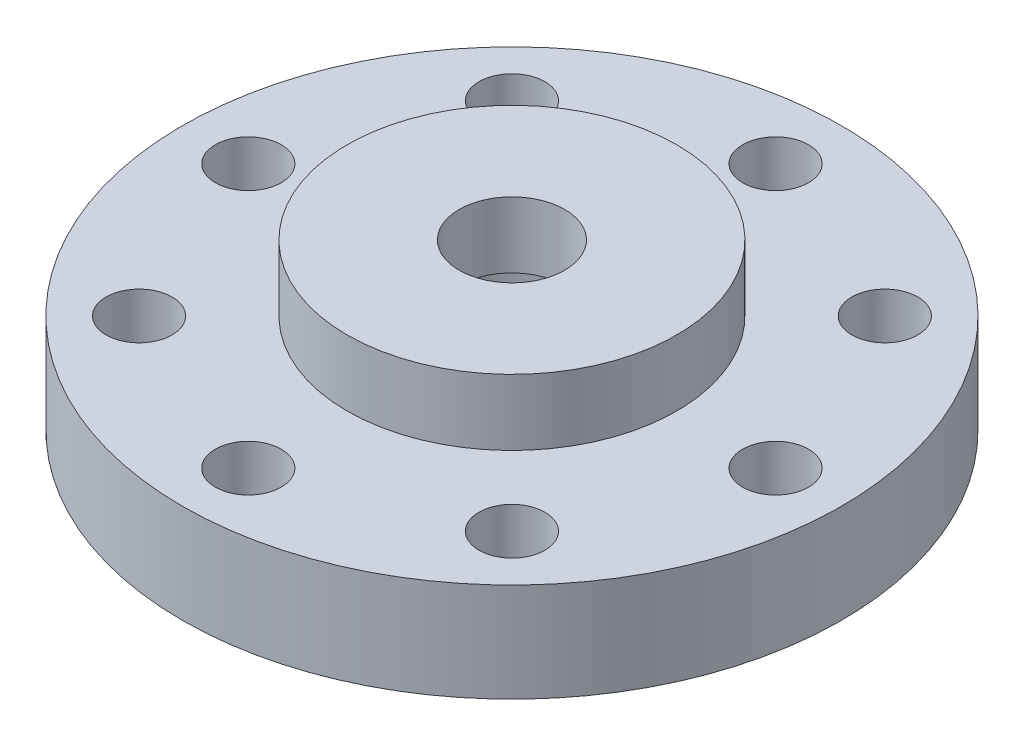
from build123d import *

# Parameters (mm, degrees)
SKETCH_1_R          = 10
EXTRUDE_1_DEPTH     = 3
SKETCH_2_R          = 5
EXTRUDE_2_DEPTH     = 2
SKETCH_3_R          = 1.6
SKETCH_3_R_2        = 1
CUT_EXTRUDE_1_DEPTH = 6
SKETCH_4_R          = 3
CUT_EXTRUDE_2_DEPTH = 3


with BuildPart() as part:
    # 草图1 → 凸台-拉伸1 (new body)
    with BuildSketch(Plane(origin=(0, 0, 0), x_dir=(1, 0, 0), z_dir=(0, 1, 0))):
        Circle(SKETCH_1_R)
    extrude(amount=EXTRUDE_1_DEPTH)

    # 草图2 → 凸台-拉伸2 (add)
    with BuildSketch(Plane(origin=(0, 3, 0), x_dir=(1, 0, 0), z_dir=(0, 1, 0))):
        Circle(SKETCH_2_R)
    extrude(amount=EXTRUDE_2_DEPTH)

    # 草图3 → 切除-拉伸1 (cut, through all)
    with BuildSketch(Plane.XZ):
        Circle(SKETCH_3_R)
        with Locations((0, 8)):
            Circle(SKETCH_3_R_2)
        with Locations((5.656854249, 5.656854249)):
            Circle(SKETCH_3_R_2)
        with Locations((8, 0)):
            Circle(SKETCH_3_R_2)
        with Locations((5.656854249, -5.656854249)):
            Circle(SKETCH_3_R_2)
        with Locations((0, -8)):
            Circle(SKETCH_3_R_2)
        with Locations((-5.656854249, -5.656854249)):
            Circle(SKETCH_3_R_2)
        with Locations((-8, 0)):
            Circle(SKETCH_3_R_2)
        with Locations((-5.656854249, 5.656854249)):
            Circle(SKETCH_3_R_2)
    extrude(amount=-CUT_EXTRUDE_1_DEPTH, mode=Mode.SUBTRACT)

    # 草图4 → 切除-拉伸2 (cut)
    with BuildSketch(Plane.XZ):
        Circle(SKETCH_4_R)
    extrude(amount=-CUT_EXTRUDE_2_DEPTH, mode=Mode.SUBTRACT)


solid = part.part
